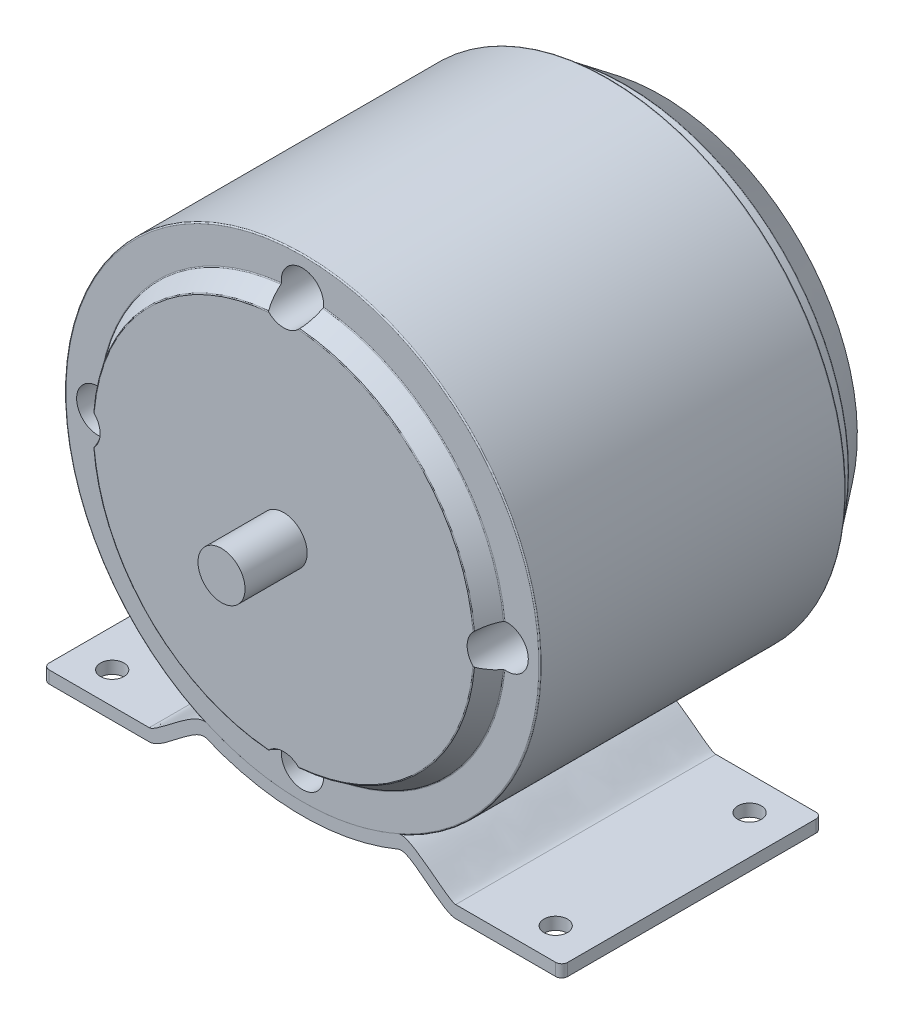
from build123d import *

# Parameters (mm, degrees)
SKETCH4_R           = 4.5
CUT_EXTRUDE1_DEPTH  = 12.7
SKETCH6_R           = 5.000000033
BOSS_EXTRUDE3_DEPTH = 13.2
BOSS_EXTRUDE6_DEPTH = 55.3
FILLET1_R           = 1.27
SKETCH9_R           = 2.5
CUT_EXTRUDE2_DEPTH  = 2.62
SKETCH10_R          = 2.5
CUT_EXTRUDE3_DEPTH  = 2.62


with BuildPart() as part:
    # Sketch3 → Revolve1 (revolve)
    with BuildSketch(Plane(origin=(0, 0, 0), x_dir=(0, 0, -1), z_dir=(1, 0, 0))):
        with BuildLine():
            Line((-45, 0), (-45, 40.363590777))
            ThreePointArc((-45, 40.363590777), (-44.969771918, 40.483766185), (-44.886282452, 40.575337875))
            Line((-44.886282452, 40.575337875), (-41.113717548, 43.074662125))
            ThreePointArc((-41.113717548, 43.074662125), (-41.030228082, 43.166233815), (-41, 43.286409223))
            Line((-41, 43.286409223), (-41, 50.246))
            ThreePointArc((-41, 50.246), (-40.925605122, 50.425605122), (-40.746, 50.5))
            Line((-40.746, 50.5), (23.746, 50.5))
            ThreePointArc((23.746, 50.5), (23.925605122, 50.425605122), (24, 50.246))
            Line((24, 50.246), (24, 47.754))
            ThreePointArc((24, 47.754), (24.074394878, 47.574394878), (24.254, 47.5))
            Line((24.254, 47.5), (27.464897133, 47.5))
            ThreePointArc((27.464897133, 47.5), (27.545591132, 47.486841189), (27.617924209, 47.448728178))
            Line((27.617924209, 47.448728178), (35.199027076, 41.726218272))
            ThreePointArc((35.199027076, 41.726218272), (35.273359712, 41.636731259), (35.3, 41.523490094))
            Line((35.3, 41.523490094), (35.3, 16.504))
            ThreePointArc((35.3, 16.504), (35.374394878, 16.324394878), (35.554, 16.25))
            Line((35.554, 16.25), (43.73, 16.25))
            ThreePointArc((43.73, 16.25), (44.628025612, 15.878025612), (45, 14.98))
            Line((45, 14.98), (45, 0))
            Line((45, 0), (-45, 0))
        make_face()
    revolve(axis=Axis((0, 0, 45), (0, 0, -1)))

    # Sketch4 → Cut-Extrude1 (cut)
    with BuildSketch(Plane.XY.offset(45)):
        with Locations((0, 43.5)):
            Circle(SKETCH4_R)
        with Locations((43.5, 0)):
            Circle(SKETCH4_R)
        with Locations((0, -43.5)):
            Circle(SKETCH4_R)
        with Locations((-43.5, 0)):
            Circle(SKETCH4_R)
    extrude(amount=-CUT_EXTRUDE1_DEPTH, mode=Mode.SUBTRACT)

    # Sketch6 → Boss-Extrude3 (add)
    with BuildSketch(Plane.XY.offset(45)):
        Circle(SKETCH6_R)
    extrude(amount=BOSS_EXTRUDE3_DEPTH)


with BuildPart() as body_2:
    # Sketch8 → Boss-Extrude6 (new body)
    with BuildSketch(Plane.XY.offset(41)):
        with BuildLine():
            Line((-55.1, -55.5), (-32.56, -55.5))
            add(Edge.make_bspline(
                [(-20.38, -48.779806847), (-22.984715863, -47.713075889), (-29.427633883, -55.5), (-32.56, -55.5)],
                knots=[0, 0, 0, 0, 1, 1, 1, 1], degree=3))
            ThreePointArc((-20.38, -48.779806847), (0, -52.866), (20.38, -48.779806847))
            add(Edge.make_bspline(
                [(20.38, -48.779806847), (22.984715863, -47.713075889), (29.427633883, -55.5), (32.56, -55.5)],
                knots=[0, 0, 0, 0, 1, 1, 1, 1], degree=3))
            Line((32.56, -55.5), (55.1, -55.5))
            Line((55.1, -55.5), (55.1, -52.88))
            Line((55.1, -52.88), (32.56, -52.88))
            add(Edge.make_bspline(
                [(20.38, -45.927291625), (23.000125007, -44.854250033), (30.737567395, -52.88), (32.56, -52.88)],
                knots=[0, 0, 0, 0, 1, 1, 1, 1], degree=3))
            ThreePointArc((20.38, -45.927291625), (0, -50.246), (-20.38, -45.927291625))
            add(Edge.make_bspline(
                [(-20.38, -45.927291625), (-23.000125007, -44.854250033), (-30.737567395, -52.88), (-32.56, -52.88)],
                knots=[0, 0, 0, 0, 1, 1, 1, 1], degree=3))
            Line((-32.56, -52.88), (-55.1, -52.88))
            Line((-55.1, -52.88), (-55.1, -55.5))
        make_face()
    extrude(amount=-BOSS_EXTRUDE6_DEPTH)

    # Fillet1
    fillet1_edges = [body_2.edges().sort_by_distance(p)[0] for p in [
        (-55.1, -54.19, -14.3),
        (55.1, -54.19, 41),
        (-55.1, -54.19, 41),
        (55.1, -54.19, -14.3),
    ]]
    fillet(fillet1_edges, radius=FILLET1_R)

    # Sketch9 → Cut-Extrude2 (cut)
    with BuildSketch(Plane.XZ.offset(55.5)):
        with Locations((47.099999904, 34.28)):
            Circle(SKETCH9_R)
        with Locations((46.87, -7.16)):
            Circle(SKETCH9_R)
    extrude(amount=-CUT_EXTRUDE2_DEPTH, mode=Mode.SUBTRACT)

    # Sketch10 → Cut-Extrude3 (cut)
    with BuildSketch(Plane.XZ.offset(55.5)):
        with Locations((-47.149999978, 34.279999978)):
            Circle(SKETCH10_R)
        with Locations((-46.9, -7.36)):
            Circle(SKETCH10_R)
    extrude(amount=-CUT_EXTRUDE3_DEPTH, mode=Mode.SUBTRACT)


solid = Compound([part.part, body_2.part])
